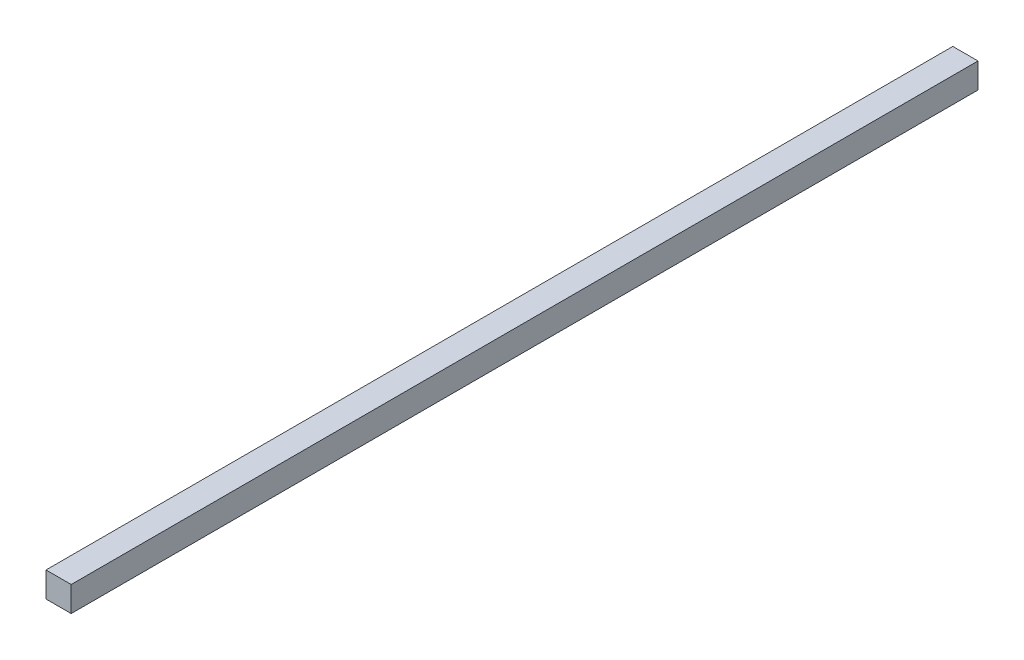
from build123d import *

# Parameters (mm, degrees)
SKETCH1_W           = 25.4
SKETCH1_H           = 25.4
BOSS_EXTRUDE1_DEPTH = 914.4


with BuildPart() as part:
    # Sketch1 → Boss-Extrude1 (new body)
    with BuildSketch(Plane.XY):
        Rectangle(SKETCH1_W, SKETCH1_H)
    extrude(amount=BOSS_EXTRUDE1_DEPTH)


solid = part.part
